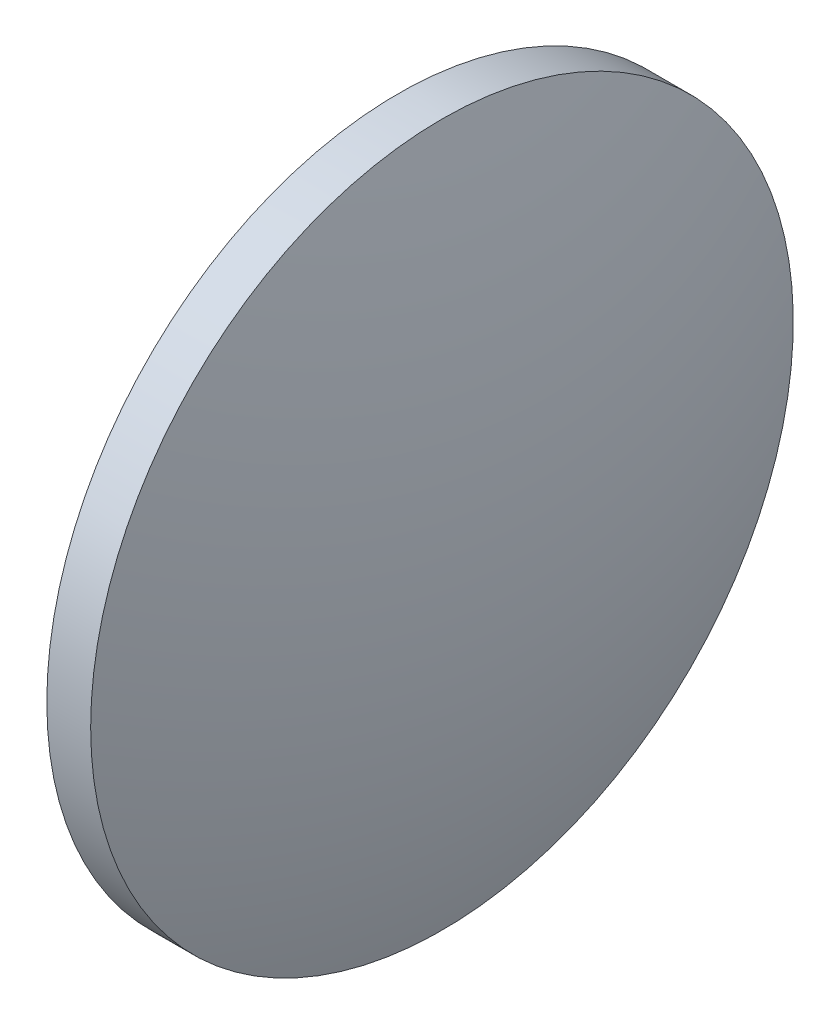
from build123d import *


with BuildPart() as part:
    # 草图1 → 旋转1 (revolve)
    with BuildSketch(Plane.XY):
        with BuildLine():
            Line((482.646392222, 32.31075154), (482.646392222, 44.81075154))
            Line((482.646392222, 44.81075154), (484.206392222, 44.81075154))
            ThreePointArc((484.206392222, 44.81075154), (485.733040841, 38.643436594), (486.246392222, 32.31075154))
            Line((486.246392222, 32.31075154), (482.646392222, 32.31075154))
        make_face()
    revolve(axis=Axis((480.617284644, 32.31075154, 0), (1, 0, 0)))


solid = part.part
